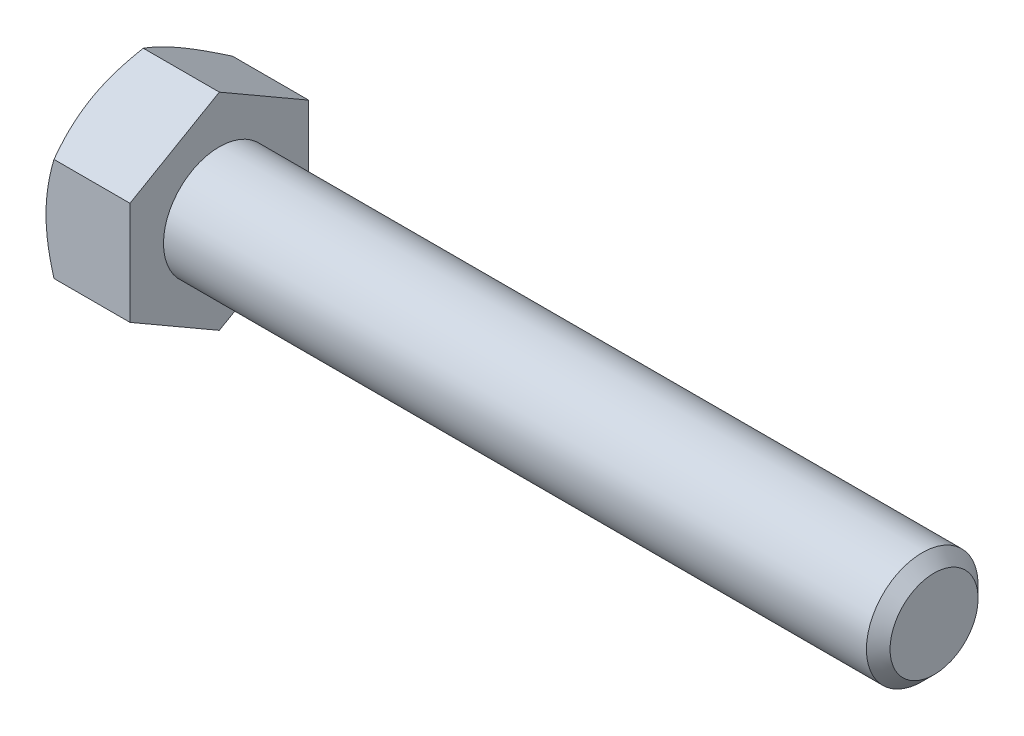
from build123d import *

# Parameters (mm, degrees)
BASEHEAD_DEPTH = 5.969


with BuildPart() as part:
    # Sketch1 → BaseHead (new body)
    with BuildSketch(Plane(origin=(0, 0, 0), x_dir=(0, 0, -1), z_dir=(1, 0, 0))):
        Polygon((6.35, 3.666174209), (6.35, -3.666174209), (0, -7.332348419), (-6.35, -3.666174209), (-6.35, 3.666174209), (0, 7.332348419), align=None)
    extrude(amount=BASEHEAD_DEPTH)

    # BodySke → BaseBody (revolve)
    with BuildSketch(Plane.XY):
        Polygon((0, 0), (56.769, 0), (56.769, 3.12928), (55.92953, 3.96875), (0, 3.96875), align=None)
    revolve(axis=Axis((0, 0, 0), (1, 0, 0)))

    # Sketch3 → HeadChamfer (revolve, cut)
    with BuildSketch(Plane.XY):
        Polygon((0, 6.35), (4.233333333, 13.682348419), (4.233333333, 20.032348419), (-12.7, 20.032348419), (-12.7, 6.35), align=None)
    revolve(axis=Axis((0, 0, 0), (1, 0, 0)), mode=Mode.SUBTRACT)


solid = part.part
